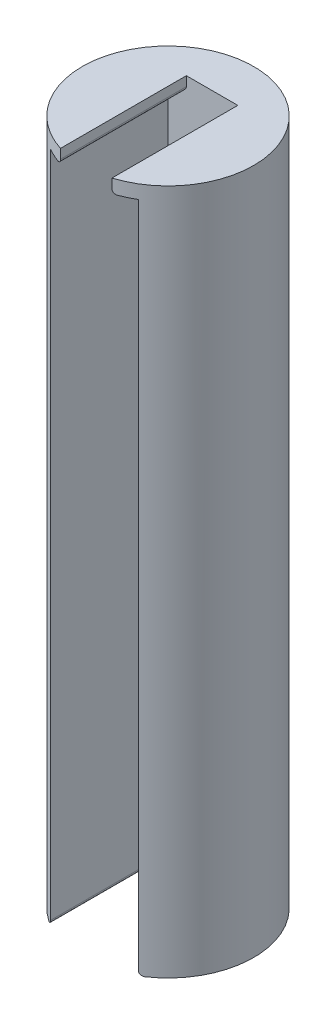
from build123d import *

# Parameters (mm, degrees)
CYLINDER_SKETCH_R              = 6.35
CYLINDER_DEPTH                 = 50.8
SKETCH2_W                      = 6.5278
SKETCH2_H                      = 49.8
SKETCH2_W_2                    = 3.81
SKETCH2_H_2                    = 1
CUT_EXTRUDE2_DEPTH             = 3.2639
CUT_EXTRUDE2_DIRECTION_2_REACH = 8.35
FILLET1_R                      = 0.3


with BuildPart() as part:
    # cylinder_sketch → cylinder (new body)
    with BuildSketch(Plane(origin=(0, 0, 0), x_dir=(1, 0, 0), z_dir=(0, 1, 0))):
        Circle(CYLINDER_SKETCH_R)
    extrude(amount=CYLINDER_DEPTH)

    # Sketch2 → Cut-Extrude2 (cut)
    with BuildSketch(Plane.XY):
        with Locations((0, 24.9)):
            Rectangle(SKETCH2_W, SKETCH2_H)
        with Locations((0, 50.3)):
            Rectangle(SKETCH2_W_2, SKETCH2_H_2)
    extrude(amount=-CUT_EXTRUDE2_DEPTH, mode=Mode.SUBTRACT)

    # Sketch2 → Cut-Extrude2 direction 2 (cut, up to next)
    with BuildSketch(Plane.XY, mode=Mode.PRIVATE) as cut_extrude2_direction_2_sk1:
        with Locations((0, 24.9)):
            Rectangle(SKETCH2_W, SKETCH2_H)
    cut_extrude2_direction_2_tool1 = extrude(cut_extrude2_direction_2_sk1.sketch, amount=CUT_EXTRUDE2_DIRECTION_2_REACH, mode=Mode.PRIVATE) & part.part
    add(cut_extrude2_direction_2_tool1.solids().sort_by_distance((0, 24.9, 0))[0], mode=Mode.SUBTRACT)
    # Sketch2 → Cut-Extrude2 direction 2 (cut, up to next)
    with BuildSketch(Plane.XY, mode=Mode.PRIVATE) as cut_extrude2_direction_2_sk2:
        with Locations((0, 50.3)):
            Rectangle(SKETCH2_W_2, SKETCH2_H_2)
    cut_extrude2_direction_2_tool2 = extrude(cut_extrude2_direction_2_sk2.sketch, amount=CUT_EXTRUDE2_DIRECTION_2_REACH, mode=Mode.PRIVATE) & part.part
    add(cut_extrude2_direction_2_tool2.solids().sort_by_distance((0, 50.3, 0))[0], mode=Mode.SUBTRACT)

    # Fillet1
    fillet1_edges = [part.edges().sort_by_distance(p)[0] for p in [
        (1.905, 49.8, 1.396806964),
        (-1.905, 49.8, 1.396806964),
        (-3.2639, 0, 1.091533835),
        (3.2639, 0, 1.091533835),
    ]]
    fillet(fillet1_edges, radius=FILLET1_R)


solid = part.part
